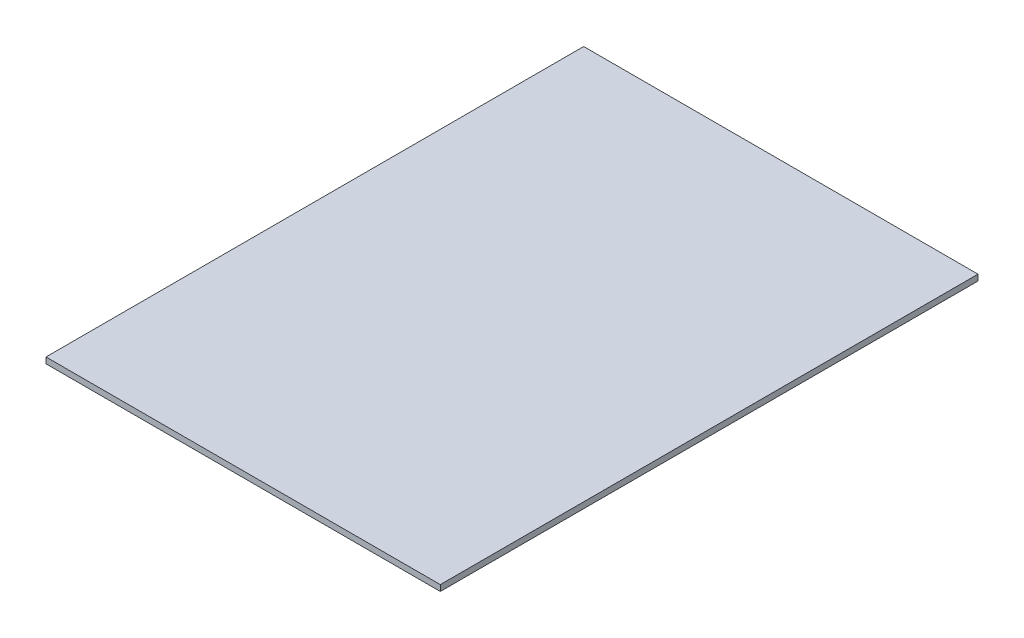
from build123d import *

# Parameters (mm, degrees)
SKETCH1_W           = 1676.4
SKETCH1_H           = 2286
BOSS_EXTRUDE1_DEPTH = 25.4


with BuildPart() as part:
    # Sketch1 → Boss-Extrude1 (new body)
    with BuildSketch(Plane(origin=(0, 0, 0), x_dir=(1, 0, 0), z_dir=(0, 1, 0))):
        with Locations((838.2, -1143)):
            Rectangle(SKETCH1_W, SKETCH1_H)
    extrude(amount=BOSS_EXTRUDE1_DEPTH)


solid = part.part
